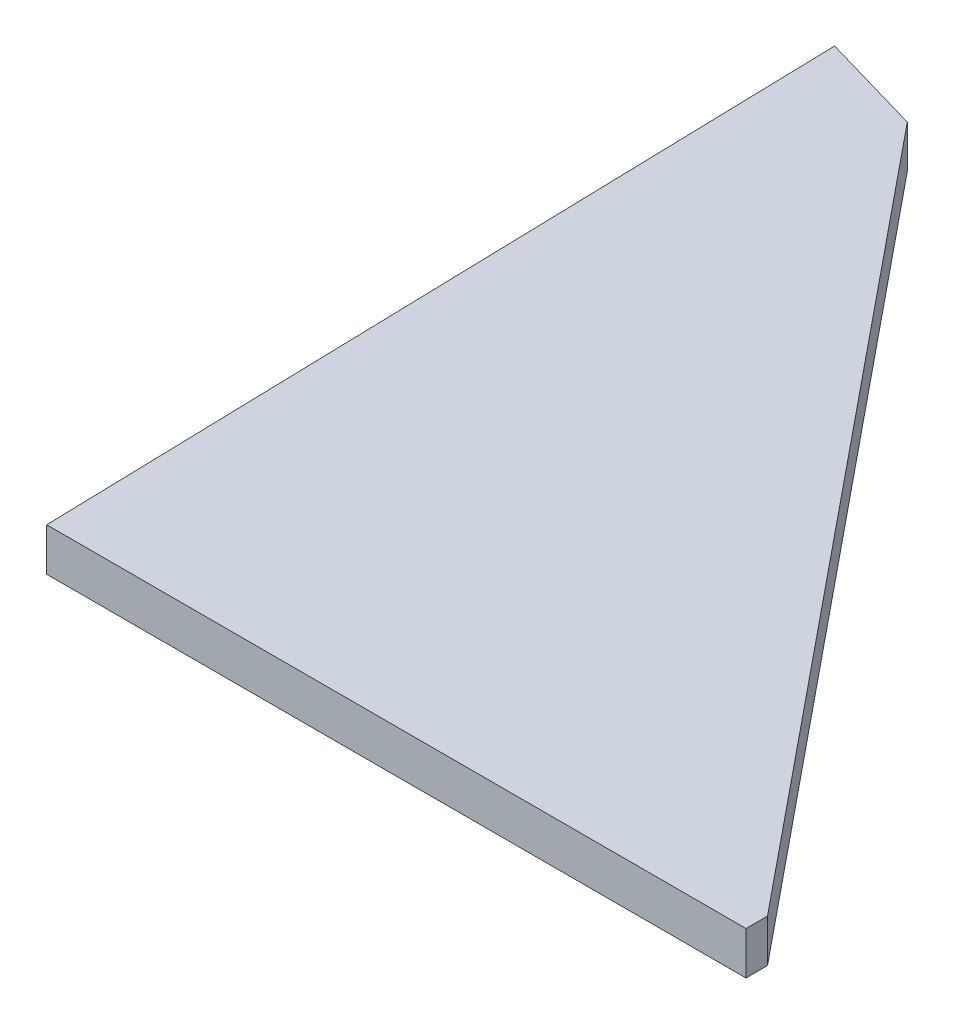
from build123d import *

# Parameters (mm, degrees)
BOSS_EXTRU_1_DEPTH = 2


with BuildPart() as part:
    # Esquisse1 → Boss.-Extru.1 (new body)
    with BuildSketch(Plane(origin=(0, 0, 0), x_dir=(1, 0, 0), z_dir=(0, 1, 0))):
        Polygon((32.622907632, 1.004416548), (3.80529815, 36.343804042), (-0.965630187, 37.724439731), (0, 0), (32.622907632, 0), align=None)
    extrude(amount=BOSS_EXTRU_1_DEPTH)


solid = part.part
